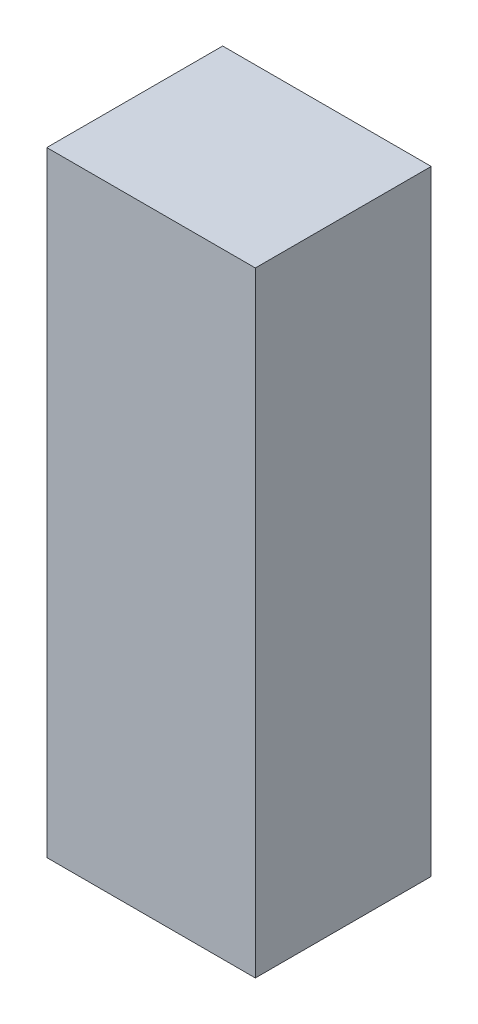
from build123d import *

# Parameters (mm, degrees)
SKETCH1_W           = 46.6
SKETCH1_H           = 39.3
BOSS_EXTRUDE1_DEPTH = 137.4


with BuildPart() as part:
    # Sketch1 → Boss-Extrude1 (new body)
    with BuildSketch(Plane(origin=(0, 0, 0), x_dir=(1, 0, 0), z_dir=(0, 1, 0))):
        with Locations((23.3, 19.65)):
            Rectangle(SKETCH1_W, SKETCH1_H)
    extrude(amount=BOSS_EXTRUDE1_DEPTH)


solid = part.part
